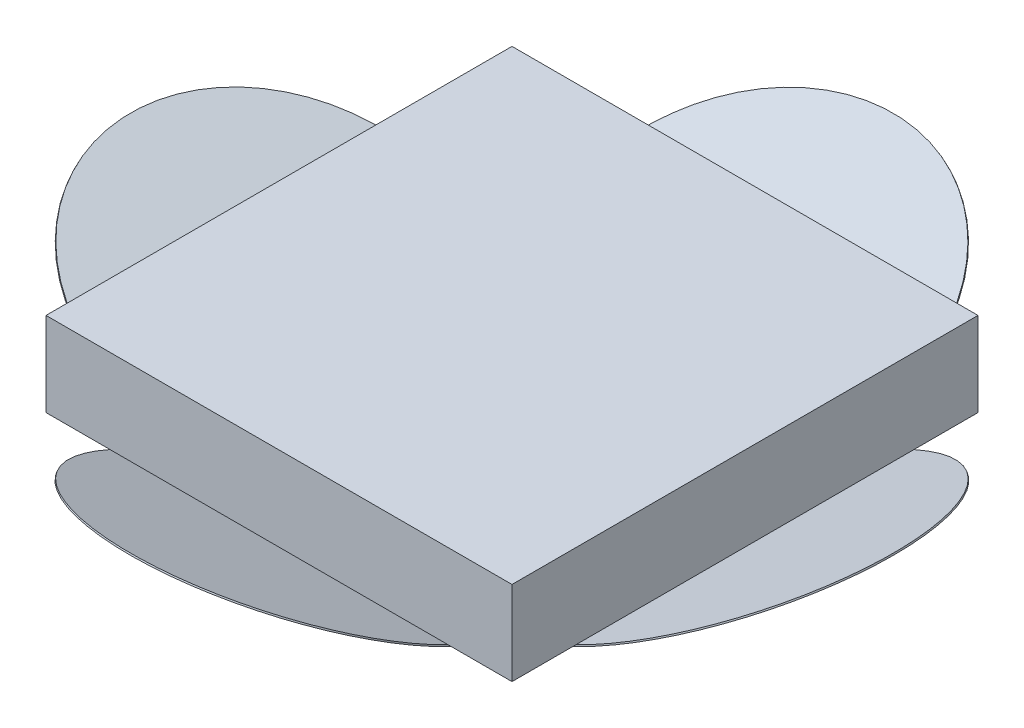
from build123d import *

# Parameters (mm, degrees)
SALIENTE_EXTRUIR1_DEPTH = 32
CORTAR_EXTRUIR1_DEPTH   = 33
CROQUIS3_R              = 11.604472628
SALIENTE_EXTRUIR2_DEPTH = 0.1
CROQUIS4_R              = 11.609993134
SALIENTE_EXTRUIR3_DEPTH = 0.1
CROQUIS6_R              = 11.602426911
SALIENTE_EXTRUIR4_DEPTH = 0.1
CROQUIS7_R              = 11.59621687
SALIENTE_EXTRUIR5_DEPTH = 0.1


with BuildPart() as part:
    # Croquis1 → Saliente-Extruir1 (new body)
    with BuildSketch(Plane.XY):
        Polygon((-51.959662641, 8.927829358), (-51.959662641, 3.148169014), (-35.959662641, -4.290206314), (-19.959662641, 3.148169014), (-19.959662641, 8.927829358), align=None)
    extrude(amount=SALIENTE_EXTRUIR1_DEPTH)

    # Croquis2 → Cortar-Extruir1 (cut)
    with BuildSketch(Plane(origin=(-19.959662641, 0, 0), x_dir=(0, 0, -1), z_dir=(1, 0, 0))):
        Polygon((0, -4.290206314), (-16, -4.290206314), (0, 3.148169014), align=None)
        Polygon((-32, -4.290206314), (-32, 3.148169014), (-16, -4.290206314), align=None)
    extrude(amount=-CORTAR_EXTRUIR1_DEPTH, mode=Mode.SUBTRACT)

    # Croquis3 → Saliente-Extruir2 (add)
    with BuildSketch(Plane(origin=(-4.750700642, 10.218791996, 0), x_dir=(-0.9067966272160485, -0.42156835373353035, 0), z_dir=(0.42156835373353035, -0.9067966272160485, 0))):
        with Locations(Location((17.141516117, -16, 0), (0, 0, 312.201634939))):
            Circle(CROQUIS3_R)
    extrude(amount=SALIENTE_EXTRUIR2_DEPTH)

    # Croquis4 → Saliente-Extruir3 (add)
    with BuildSketch(Plane(origin=(0, -9.644179557, 4.483564205), x_dir=(-1, 0, 0), z_dir=(0, -0.9067966272160485, 0.4215683537335304))):
        with Locations(Location((35.959662641, -29.983548914, 0), (0, 0, 181.782387553))):
            Circle(CROQUIS4_R)
    extrude(amount=SALIENTE_EXTRUIR3_DEPTH)

    # Croquis6 → Saliente-Extruir4 (add)
    with BuildSketch(Plane(origin=(-8.030792992, -17.274294748, 0), x_dir=(-0.9067966272160486, 0.4215683537335302, 0), z_dir=(-0.4215683537335302, -0.9067966272160486, 0))):
        with Locations(Location((48.071640088, -16, 0), (0, 0, 271.839200589))):
            Circle(CROQUIS6_R)
    extrude(amount=SALIENTE_EXTRUIR4_DEPTH)

    # Croquis7 → Saliente-Extruir5 (add)
    with BuildSketch(Plane(origin=(0, 2.588676805, 1.203471855), x_dir=(-1, 0, 0), z_dir=(0, -0.9067966272160485, -0.4215683537335304))):
        with Locations(Location((35.959662641, 0.945548569, 0), (0, 0, 317.815283521))):
            Circle(CROQUIS7_R)
    extrude(amount=SALIENTE_EXTRUIR5_DEPTH)


solid = part.part
